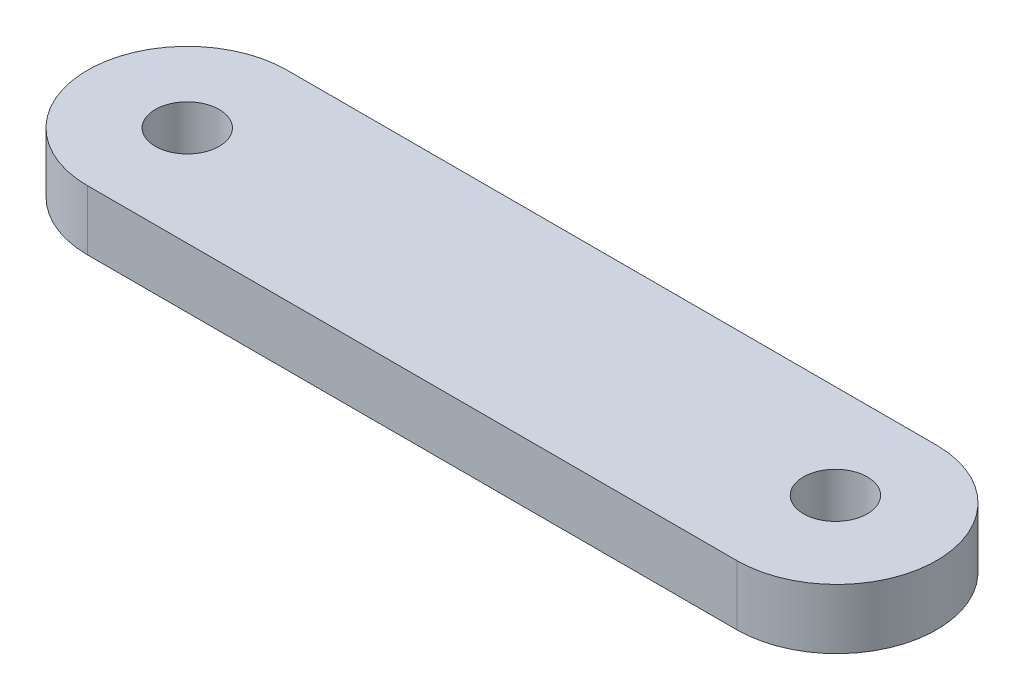
from build123d import *

# Parameters (mm, degrees)
SKETCH1_R           = 1.6
BOSS_EXTRUDE1_DEPTH = 3


with BuildPart() as part:
    # Sketch1 → Boss-Extrude1 (new body)
    with BuildSketch(Plane(origin=(0, 0, 0), x_dir=(1, 0, 0), z_dir=(0, 1, 0))):
        with BuildLine():
            Line((-37.664251208, 1.125), (-5.164251208, 1.125))
            ThreePointArc((-5.164251208, 1.125), (-0.164251208, -3.875), (-5.164251208, -8.875))
            Line((-5.164251208, -8.875), (-37.664251208, -8.875))
            ThreePointArc((-37.664251208, -8.875), (-42.664251208, -3.875), (-37.664251208, 1.125))
        make_face()
        with Locations((-37.664251208, -3.875)):
            Circle(SKETCH1_R, mode=Mode.SUBTRACT)
        with Locations((-5.52442378, -3.582463022)):
            Circle(SKETCH1_R, mode=Mode.SUBTRACT)
    extrude(amount=BOSS_EXTRUDE1_DEPTH)


solid = part.part
